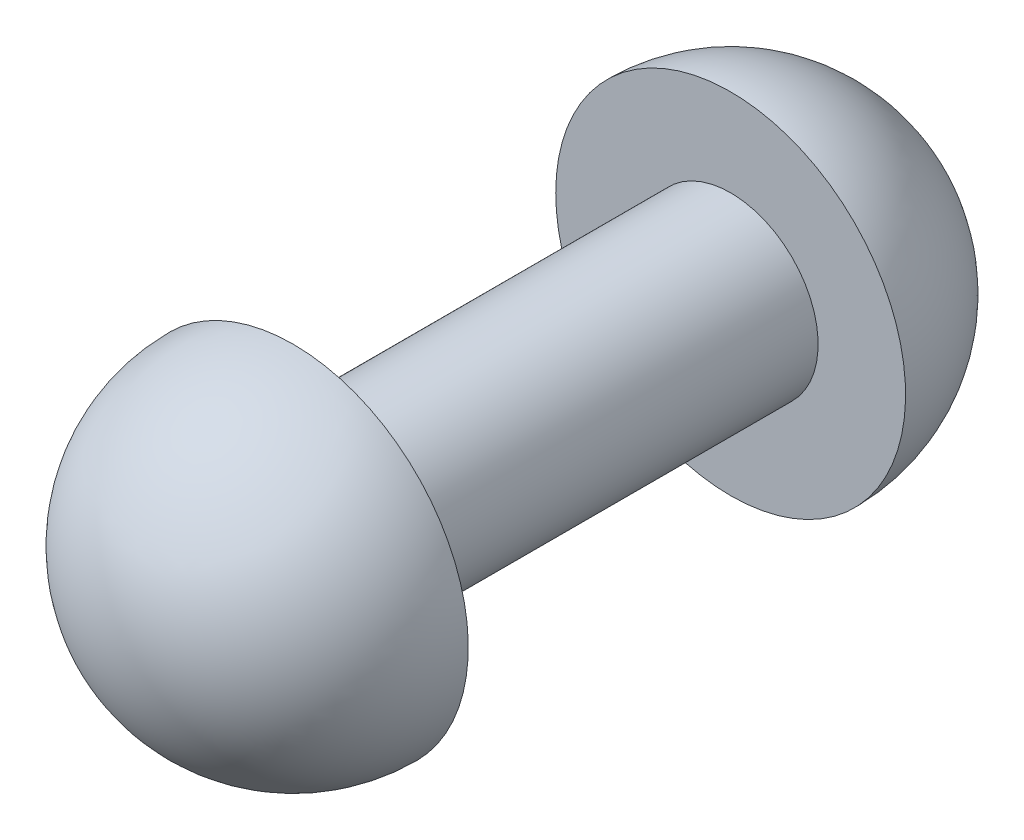
from build123d import *


with BuildPart() as part:
    # Sketch2 → Revolve1 (revolve)
    with BuildSketch(Plane(origin=(0, 0, 0), x_dir=(0, 0, -1), z_dir=(1, 0, 0))):
        with BuildLine():
            Line((-7.5, 3), (7.5, 3))
            Line((7.5, 3), (7.5, 6))
            ThreePointArc((7.5, 6), (11.742640687, 4.242640687), (13.5, 0))
            Line((13.5, 0), (-13.5, 0))
            ThreePointArc((-13.5, 0), (-11.742640687, 4.242640687), (-7.5, 6))
            Line((-7.5, 6), (-7.5, 3))
        make_face()
    revolve(axis=Axis((0, 0, -17.85), (0, 0, 1)))


solid = part.part
